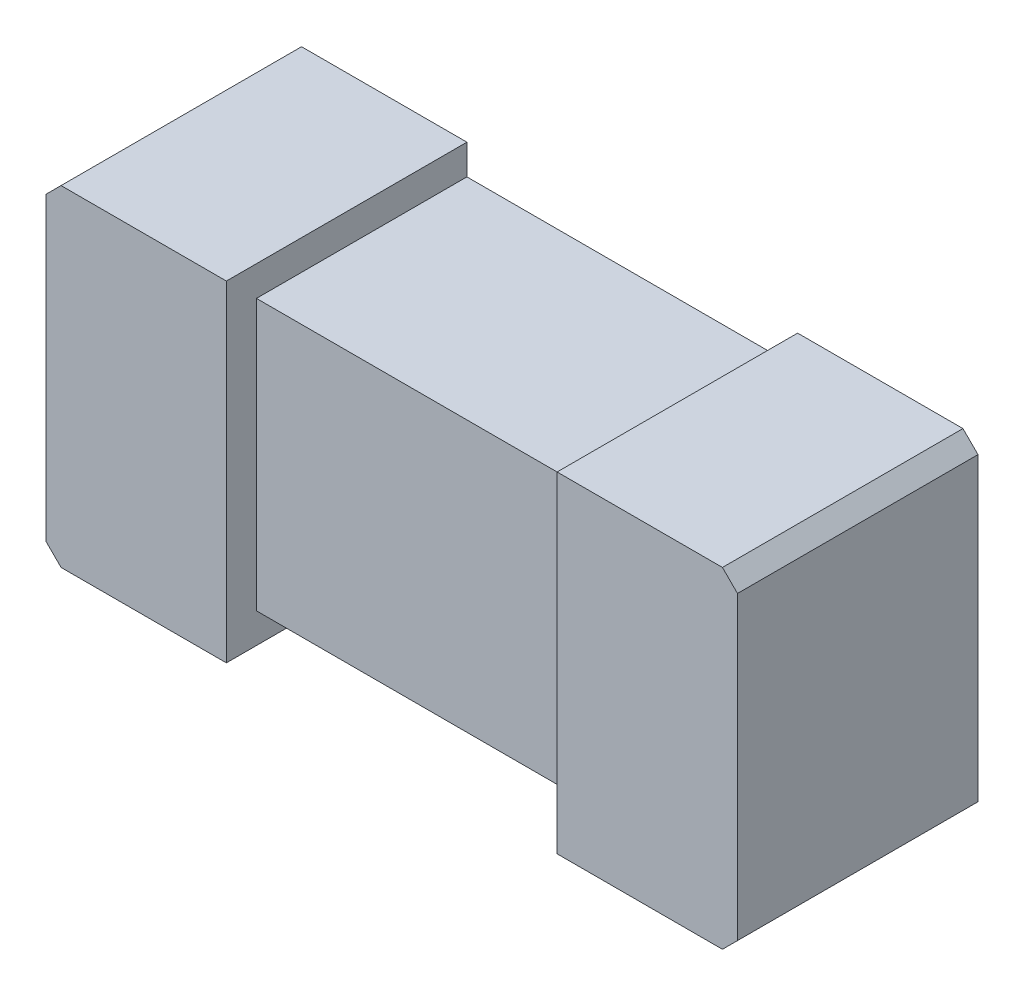
from build123d import *

# Parameters (mm, degrees)
EXTRUDE1_DEPTH     = 0.4
SKETCH1_W          = 0.55
SKETCH1_H          = 0.05
CUT_EXTRUDE1_DEPTH = 1.4
SKETCH2_W          = 0.55
SKETCH2_H          = 0.05
CUT_EXTRUDE2_DEPTH = 5


with BuildPart() as part:
    # COMPONENT_OUTLINE → Extrude1 (new body)
    with BuildSketch(Plane.XY):
        Polygon((0.55, 0.275), (-0.55, 0.275), (-0.575, 0.25), (-0.575, -0.25), (-0.55, -0.275), (0.55, -0.275), (0.575, -0.25), (0.575, 0.25), align=None)
    extrude(amount=EXTRUDE1_DEPTH)

    # Sketch1 → Cut-Extrude1 (cut, through all)
    with BuildSketch(Plane.XY.offset(0.4)):
        with Locations((0, 0.25)):
            Rectangle(SKETCH1_W, SKETCH1_H)
        with Locations((0, -0.25)):
            Rectangle(SKETCH1_W, SKETCH1_H)
    extrude(amount=-CUT_EXTRUDE1_DEPTH, mode=Mode.SUBTRACT)

    # Sketch2 → Cut-Extrude2 (cut)
    with BuildSketch(Plane.XZ.offset(0.225)):
        with Locations((0, 0.375)):
            Rectangle(SKETCH2_W, SKETCH2_H)
    extrude(amount=-CUT_EXTRUDE2_DEPTH, mode=Mode.SUBTRACT)


solid = part.part
